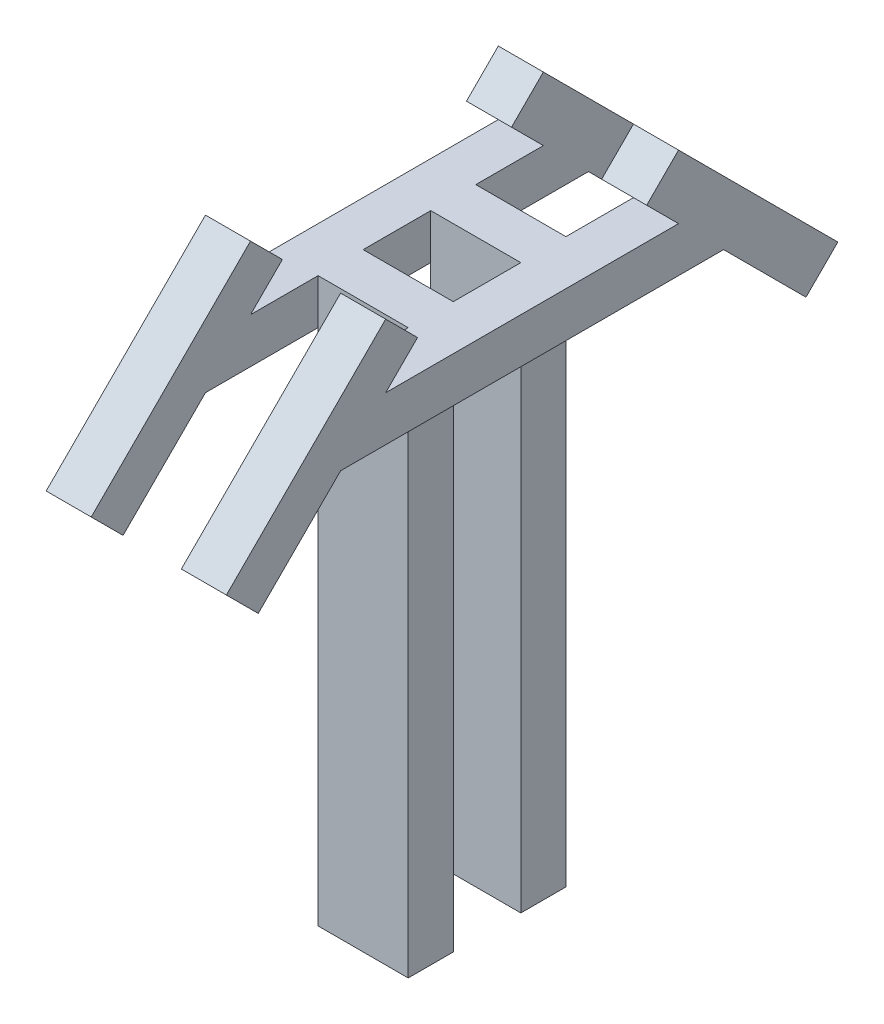
from build123d import *

# Parameters (mm, degrees)
SKETCH_1_W               = 80
SKETCH_1_H               = 40
EXTRUDE_1_DEPTH          = 500
EXTRUDE_1_2_DEPTH        = 500
SKETCH_2_W               = 340
SKETCH_2_H               = 40
EXTRUDE_2_DEPTH          = 40
SKETCH_3_W               = 340
SKETCH_3_H               = 40
EXTRUDE_3_DEPTH          = 40
CUT_EXTRUDE_1_DEPTH      = 1
CUT_EXTRUDE_1_DEPTH_BACK = 161
SKETCH_5_W               = 40
SKETCH_5_H               = 200
EXTRUDE_4_DEPTH          = 40
SKETCH_6_W               = 40
SKETCH_6_H               = 200
EXTRUDE_5_DEPTH          = 40


with BuildPart() as part:
    # 草图1 → 凸台-拉伸1 (new body)
    with BuildSketch(Plane(origin=(0, 0, 0), x_dir=(1, 0, 0), z_dir=(0, 1, 0))):
        with Locations((40, -20)):
            Rectangle(SKETCH_1_W, SKETCH_1_H)
    extrude(amount=EXTRUDE_1_DEPTH)



with BuildPart() as body_2:
    # 草图1 → Extrude 1 2 (new body)
    with BuildSketch(Plane(origin=(0, 0, 0), x_dir=(1, 0, 0), z_dir=(0, 1, 0))):
        with Locations((40, 80)):
            Rectangle(SKETCH_1_W, SKETCH_1_H)
    extrude(amount=EXTRUDE_1_2_DEPTH)


with BuildPart() as part_1:
    add(part.part)

    add(body_2.part)  # 凸台-拉伸2 merges body 2
    # 草图2 → 凸台-拉伸2 (add)
    with BuildSketch(Plane(origin=(80, 0, 0), x_dir=(0, 0, -1), z_dir=(1, 0, 0))):
        with Locations((30, 480)):
            Rectangle(SKETCH_2_W, SKETCH_2_H)
    extrude(amount=EXTRUDE_2_DEPTH)

    # 草图3 → 凸台-拉伸3 (add)
    with BuildSketch(Plane.ZY):
        with Locations((-30, 480)):
            Rectangle(SKETCH_3_W, SKETCH_3_H)
    extrude(amount=EXTRUDE_3_DEPTH)

    # 草图4 → 切除-拉伸1 (cut, two sides)
    with BuildSketch(Plane.ZY.offset(40)) as cut_extrude_1_sk:
        Polygon((140, 460), (100, 500), (140, 500), align=None)
        Polygon((-200, 460), (-160, 500), (-200, 500), align=None)
    extrude(amount=CUT_EXTRUDE_1_DEPTH, mode=Mode.SUBTRACT)
    extrude(cut_extrude_1_sk.sketch, amount=-CUT_EXTRUDE_1_DEPTH_BACK, mode=Mode.SUBTRACT)

    # 草图5 → 凸台-拉伸4 (add)
    with BuildSketch(Plane(origin=(0, 300, 300), x_dir=(1, 0, 0), z_dir=(0, 0.707106781, 0.707106781))):
        with Locations((-20, 222.842712475)):
            Rectangle(SKETCH_5_W, SKETCH_5_H)
        with Locations((100, 222.842712475)):
            Rectangle(SKETCH_5_W, SKETCH_5_H)
    extrude(amount=EXTRUDE_4_DEPTH)

    # 草图6 → 凸台-拉伸5 (add)
    with BuildSketch(Plane(origin=(0, 330, -330), x_dir=(1, 0, 0), z_dir=(0, 0.707106781, -0.707106781))):
        with Locations((100, -180.416305603)):
            Rectangle(SKETCH_6_W, SKETCH_6_H)
        with Locations((-20, -180.416305603)):
            Rectangle(SKETCH_6_W, SKETCH_6_H)
    extrude(amount=EXTRUDE_5_DEPTH)


solid = part_1.part
